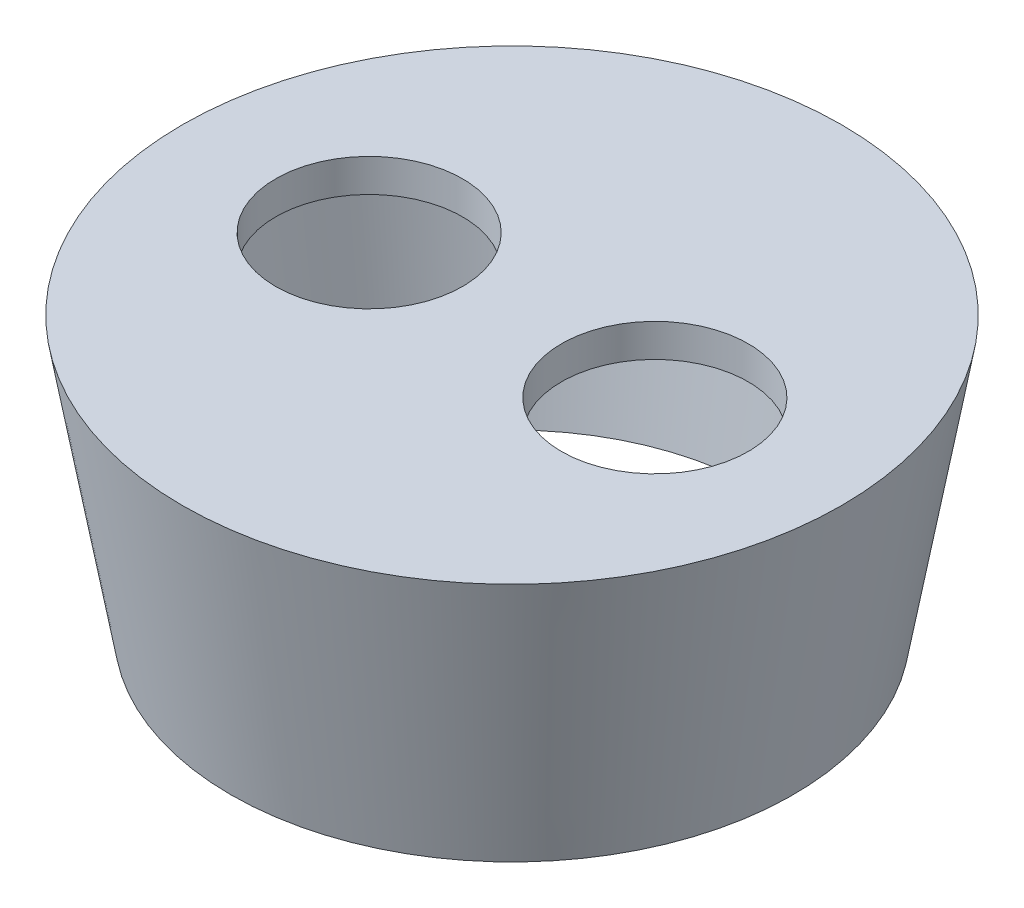
from build123d import *

# Parameters (mm, degrees)
SKETCH1_R           = 30
BOSS_EXTRUDE1_DEPTH = 25
DRAFT1_ANGLE        = -10
SHELL2_T            = -3
SKETCH1_4_R         = 8.5
CUT_EXTRUDE2_DEPTH  = 3


with BuildPart() as part:
    # Sketch1 → Boss-Extrude1 (new body)
    with BuildSketch(Plane(origin=(0, 0, 0), x_dir=(1, 0, 0), z_dir=(0, 1, 0))):
        with Locations(Location((0, 0, 0), (0, 0, 270))):
            Circle(SKETCH1_R)
    extrude(amount=-BOSS_EXTRUDE1_DEPTH)

    # Draft1
    draft1_faces = [part.faces().sort_by_distance(p)[0] for p in [
        (0, -12.5, -30),
    ]]
    draft(draft1_faces, Plane.ZX, DRAFT1_ANGLE)

    # Shell2
    shell2_openings = [part.faces().sort_by_distance(p)[0] for p in [
        (0, -25, 0),
    ]]
    offset(amount=SHELL2_T, openings=shell2_openings, kind=Kind.INTERSECTION)

    # Sketch1_4 → Cut-Extrude2 (cut)
    with BuildSketch(Plane(origin=(0, 0, 0), x_dir=(1, 0, 0), z_dir=(0, 1, 0))):
        with Locations(Location((-13, 0, 0), (0, 0, 270))):
            Circle(SKETCH1_4_R)
        with Locations(Location((13, 0, 0), (0, 0, 270))):
            Circle(SKETCH1_4_R)
    extrude(amount=-CUT_EXTRUDE2_DEPTH, mode=Mode.SUBTRACT)


solid = part.part
